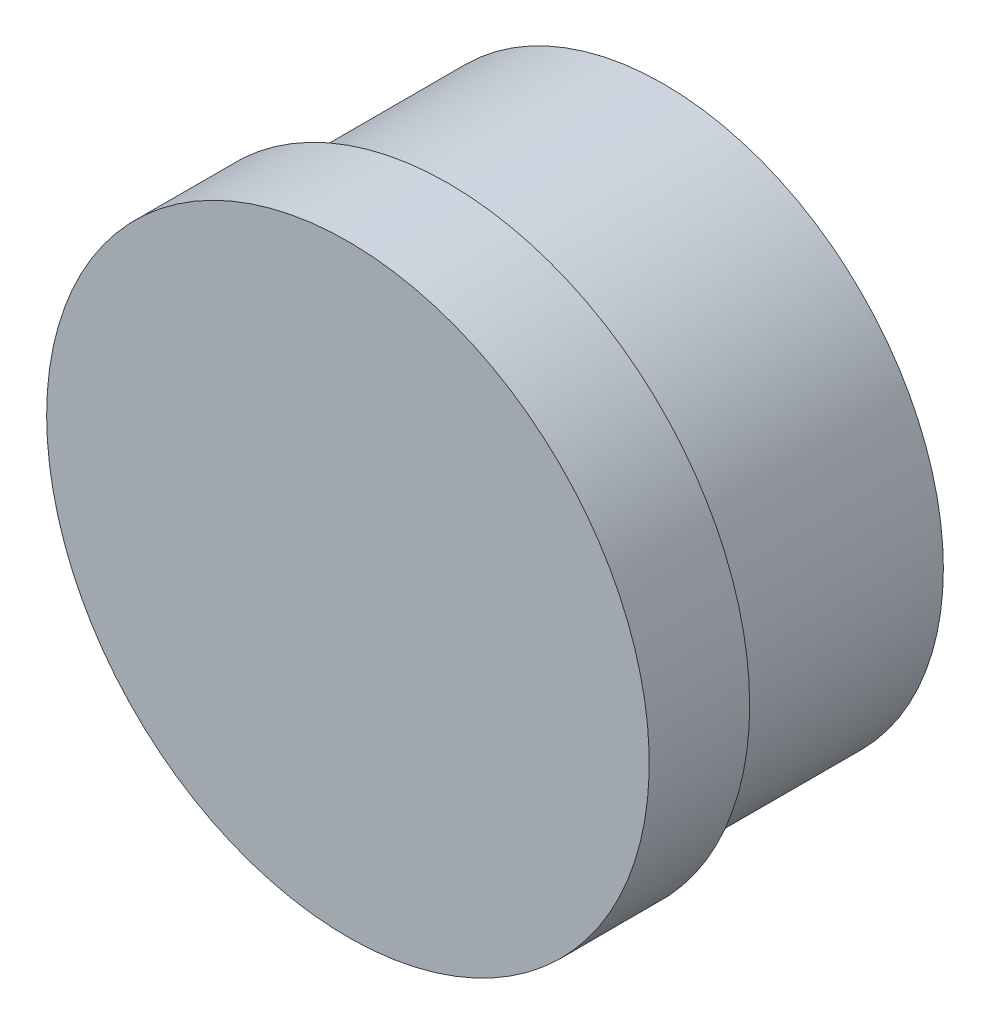
from build123d import *

# Parameters (mm, degrees)
SKETCH1_R           = 19.5
BOSS_EXTRUDE1_DEPTH = 15
SKETCH2_R           = 21
BOSS_EXTRUDE2_DEPTH = 2
SKETCH3_R           = 50
BOSS_EXTRUDE3_DEPTH = 5
CUT_EXTRUDE2_DEPTH  = 5
CUT_EXTRUDE3_DEPTH  = 2.5
SKETCH8_R           = 2.5
CUT_EXTRUDE4_DEPTH  = 20.5
BOSS_EXTRUDE4_DEPTH = 5
FILLET1_R           = 1
SKETCH10_R          = 50
SKETCH10_R_2        = 21
CUT_EXTRUDE5_DEPTH  = 28


with BuildPart() as part:
    # Sketch1 → Boss-Extrude1 (new body)
    with BuildSketch(Plane.XY):
        Circle(SKETCH1_R)
    extrude(amount=BOSS_EXTRUDE1_DEPTH)

    # Sketch2 → Boss-Extrude2 (add)
    with BuildSketch(Plane.XY.offset(15)):
        Circle(SKETCH2_R)
    extrude(amount=BOSS_EXTRUDE2_DEPTH)

    # Sketch3 → Boss-Extrude3 (add)
    with BuildSketch(Plane.XY.offset(17)):
        Circle(SKETCH3_R)
    extrude(amount=BOSS_EXTRUDE3_DEPTH)

    # Sketch4 → Cut-Extrude2 (cut)
    with BuildSketch(Plane(origin=(0, 0, 17), x_dir=(-1, 0, 0), z_dir=(0, 0, -1))):
        with BuildLine():
            ThreePointArc((-18.186533, -10.5), (-21, 0), (-18.186533, 10.5))
            Line((-18.186533, 10.5), (-36.669606, 21.484645))
            ThreePointArc((-36.669606, 21.484645), (-42.499783, 0.135723), (-36.80608, -21.25))
            Line((-36.80608, -21.25), (-18.186533, -10.5))
        make_face()
        with BuildLine():
            Line((-21.25, 36.80608), (-10.5, 18.186533))
            ThreePointArc((-10.5, 18.186533), (0, 21), (10.5, 18.186533))
            Line((10.5, 18.186533), (21.484645, 36.669606))
            ThreePointArc((21.484645, 36.669606), (0.135723, 42.499783), (-21.25, 36.80608))
        make_face()
        with BuildLine():
            Line((36.80608, 21.25), (18.186533, 10.5))
            ThreePointArc((18.186533, 10.5), (20.284442, 5.4352), (21, 0))
            ThreePointArc((21, 0), (20.284442, -5.4352), (18.186533, -10.5))
            Line((18.186533, -10.5), (36.669606, -21.484645))
            ThreePointArc((36.669606, -21.484645), (42.499783, -0.135723), (36.80608, 21.25))
        make_face()
    extrude(amount=-CUT_EXTRUDE2_DEPTH, mode=Mode.SUBTRACT)

    # Sketch5 → Cut-Extrude3 (cut)
    with BuildSketch(Plane.XY.offset(22)):
        with BuildLine():
            Line((-15, -47.69696), (-15, -27.69696))
            Line((-15, -27.69696), (15, -27.69696))
            Line((15, -27.69696), (15, -47.69696))
            ThreePointArc((15, -47.69696), (0, -50), (-15, -47.69696))
        make_face()
    extrude(amount=-CUT_EXTRUDE3_DEPTH, mode=Mode.SUBTRACT)

    # Sketch8 → Cut-Extrude4 (cut, through all)
    with BuildSketch(Plane.XY.offset(19.5)):
        with Locations((-7.5, -37.69696)):
            Circle(SKETCH8_R)
        with Locations((7.5, -37.69696)):
            Circle(SKETCH8_R)
    extrude(amount=-CUT_EXTRUDE4_DEPTH, mode=Mode.SUBTRACT)

    # Sketch9 → Boss-Extrude4 (add)
    with BuildSketch(Plane.XY.offset(22)):
        with BuildLine():
            Line((-36.80608, 21.25), (-43.30127, 25))
            ThreePointArc((-43.30127, 25), (-49.999665, -0.183068), (-43.117043, -25.31641))
            Line((-43.117043, -25.31641), (-36.669606, -21.484645))
            ThreePointArc((-36.669606, -21.484645), (-42.499783, -0.135723), (-36.80608, 21.25))
        make_face()
        with BuildLine():
            Line((-21.484645, 36.669606), (-25.31641, 43.117043))
            ThreePointArc((-25.31641, 43.117043), (-0.183068, 49.999665), (25, 43.30127))
            Line((25, 43.30127), (21.25, 36.80608))
            ThreePointArc((21.25, 36.80608), (-0.135723, 42.499783), (-21.484645, 36.669606))
        make_face()
        with BuildLine():
            Line((36.669606, 21.484645), (43.117043, 25.31641))
            ThreePointArc((43.117043, 25.31641), (49.999665, 0.183068), (43.30127, -25))
            Line((43.30127, -25), (36.80608, -21.25))
            ThreePointArc((36.80608, -21.25), (42.499783, 0.135723), (36.669606, 21.484645))
        make_face()
    extrude(amount=BOSS_EXTRUDE4_DEPTH)

    # Fillet1
    fillet1_edges = [part.edges().sort_by_distance(p)[0] for p in [
        (-0.135723, 42.499783, 27),
        (23.125, 40.053675, 27),
        (-0.183068, 49.999665, 27),
        (-23.400528, 39.893324, 27),
        (42.499783, 0.135723, 27),
        (40.053675, -23.125, 27),
        (49.999665, 0.183068, 27),
        (39.893324, 23.400528, 27),
        (-42.499783, -0.135723, 27),
        (-40.053675, 23.125, 27),
        (-49.999665, -0.183068, 27),
        (-39.893324, -23.400528, 27),
    ]]
    fillet(fillet1_edges, radius=FILLET1_R)

    # Sketch10 → Cut-Extrude5 (cut, through all)
    with BuildSketch(Plane(origin=(0, 0, 0), x_dir=(-1, 0, 0), z_dir=(0, 0, -1))):
        Circle(SKETCH10_R)
        Circle(SKETCH10_R_2, mode=Mode.SUBTRACT)
    extrude(amount=-CUT_EXTRUDE5_DEPTH, mode=Mode.SUBTRACT)


solid = part.part
